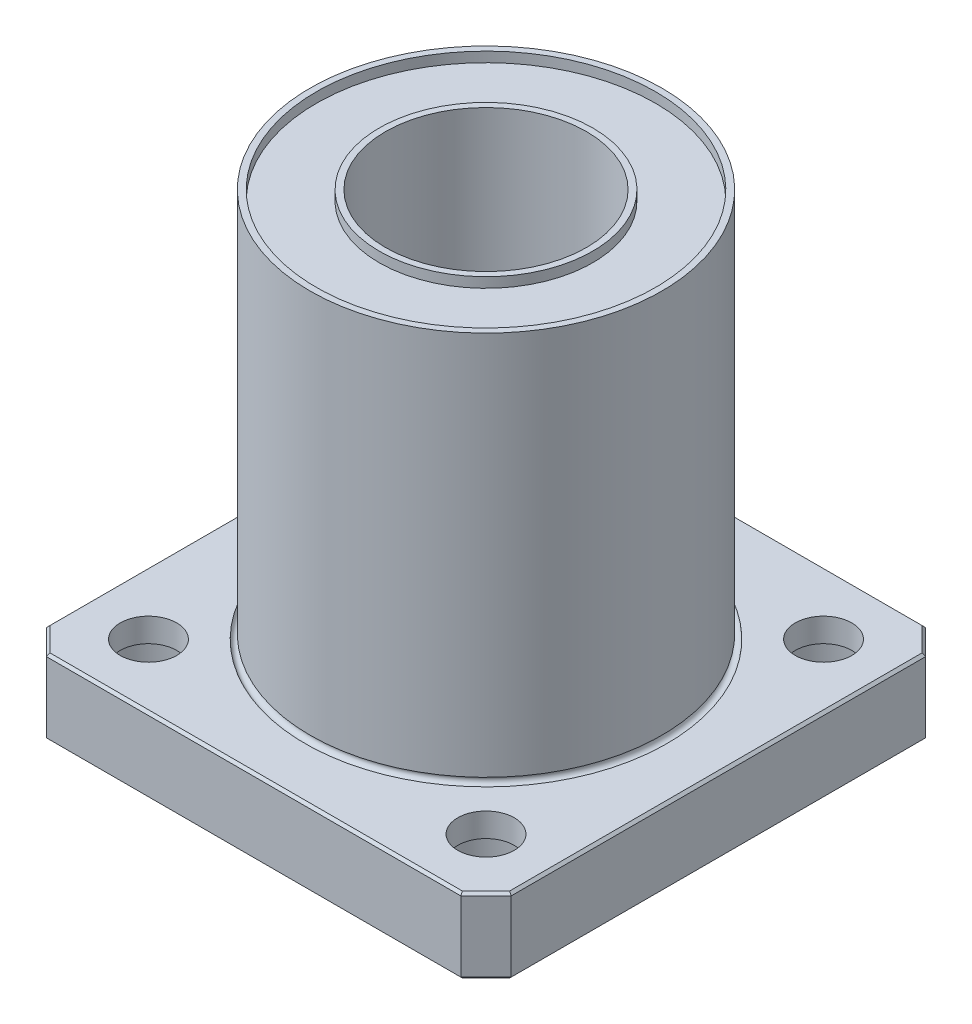
from build123d import *

# Parameters (mm, degrees)
FLANGE_DEPTH         = 6
SKETCH9_R            = 4
COUNTERBORE_DEPTH    = 4.1
SKETCH10_R           = 2.25
MOUNTING_HOLES_DEPTH = 33.9
SKETCH11_R           = 0.375
CHAMFER1_SIZE        = 0.2


with BuildPart() as part:
    # Sketch5 → Bearing Body (revolve)
    with BuildSketch(Plane(origin=(0, 0, 0), x_dir=(0, 0, -1), z_dir=(1, 0, 0))):
        Polygon((8.5, 37), (8, 37), (8, 0), (8.5, 0), (8.5, 0.8), (13.5, 0.8), (13.5, 0), (14, 0), (14, 37), (13.5, 37), (13.5, 36.2), (8.5, 36.2), align=None)
    revolve(axis=Axis((0, 0, 0), (0, 1, 0)))

    # Sketch8 → Flange (add)
    with BuildSketch(Plane(origin=(0, 0, 0), x_dir=(1, 0, 0), z_dir=(0, 1, 0))):
        Polygon((0, -18.5), (-16.5, -18.5), (-18.5, -16.5), (-18.5, 0), (-18.5, 16.5), (-16.5, 18.5), (0, 18.5), (16.5, 18.5), (18.5, 16.5), (18.5, 0), (18.5, -16.5), (16.5, -18.5), align=None)
        with BuildLine():
            ThreePointArc((-10.5, 0), (-7.424621202, -7.424621202), (0, -10.5))
            ThreePointArc((0, -10.5), (7.424621202, -7.424621202), (10.5, 0))
            ThreePointArc((10.5, 0), (7.424621202, 7.424621202), (0, 10.5))
            ThreePointArc((0, 10.5), (-7.424621202, 7.424621202), (-10.5, 0))
        make_face(mode=Mode.SUBTRACT)
    extrude(amount=FLANGE_DEPTH)

    # Sketch9 → Counterbore (cut)
    with BuildSketch(Plane(origin=(0, 0, 0), x_dir=(-1, 0, 0), z_dir=(0, -1, 0))):
        with Locations((13.435028843, -13.435028843)):
            Circle(SKETCH9_R)
        with Locations((-13.435028843, -13.435028843)):
            Circle(SKETCH9_R)
        with Locations((-13.435028843, 13.435028843)):
            Circle(SKETCH9_R)
        with Locations((13.435028843, 13.435028843)):
            Circle(SKETCH9_R)
    extrude(amount=-COUNTERBORE_DEPTH, mode=Mode.SUBTRACT)

    # Sketch10 → Mounting Holes (cut, through all)
    with BuildSketch(Plane(origin=(0, 4.1, 0), x_dir=(-1, 0, 0), z_dir=(0, -1, 0))):
        with Locations((13.435028843, 13.435028843)):
            Circle(SKETCH10_R)
        with Locations((13.435028843, -13.435028843)):
            Circle(SKETCH10_R)
        with Locations((-13.435028843, -13.435028843)):
            Circle(SKETCH10_R)
        with Locations((-13.435028843, 13.435028843)):
            Circle(SKETCH10_R)
    extrude(amount=-MOUNTING_HOLES_DEPTH, mode=Mode.SUBTRACT)

    # Sketch11 → Relief (revolve, cut)
    with BuildSketch(Plane(origin=(0, 0, 0), x_dir=(0, 0, -1), z_dir=(1, 0, 0))):
        with Locations((-14.026134699, 6)):
            Circle(SKETCH11_R)
    revolve(axis=Axis((0, 0, 0), (0, 1, 0)), mode=Mode.SUBTRACT)

    # Chamfer1
    chamfer1_edges = [part.edges().sort_by_distance(p)[0] for p in [
        (-17.5, 6, 17.5),
        (0, 6, 18.5),
        (17.5, 6, 17.5),
        (18.5, 6, 0),
        (17.5, 6, -17.5),
        (0, 6, -18.5),
        (-17.5, 6, -17.5),
        (-18.5, 6, 0),
        (-17.5, 0, 17.5),
        (0, 0, 18.5),
        (17.5, 0, 17.5),
        (18.5, 0, 0),
        (17.5, 0, -17.5),
        (0, 0, -18.5),
        (-17.5, 0, -17.5),
        (-18.5, 0, 0),
    ]]
    chamfer(chamfer1_edges, length=CHAMFER1_SIZE)


solid = part.part
